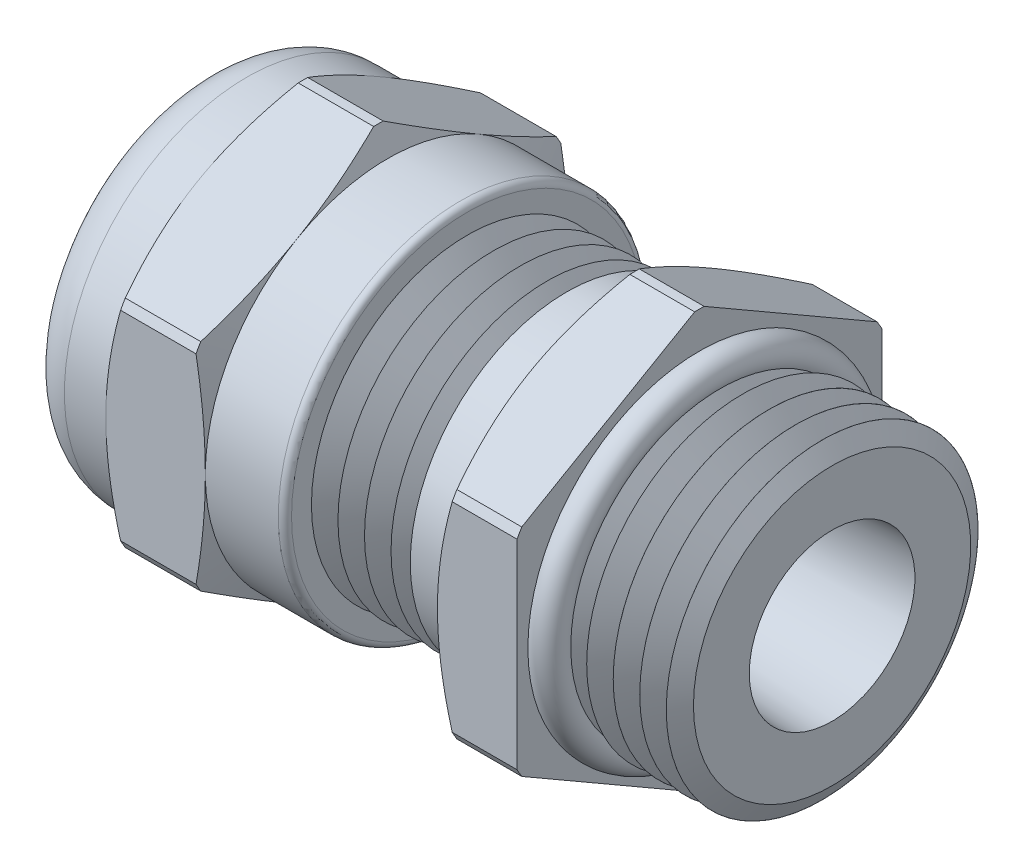
from build123d import *

# Parameters (mm, degrees)
SKETCH6_OUTSIDE_W  = 24.528
SKETCH6_OUTSIDE_H  = 24.528
CUT_EXTRUDE2_DEPTH = 15.748
SKETCH7_OUTSIDE_W  = 31.19
SKETCH7_OUTSIDE_H  = 33.146
SKETCH7_OUTSIDE_R  = 6.985
CUT_EXTRUDE3_DEPTH = 2.54
CUT_EXTRUDE3_DRAFT = -60
SKETCH8_OUTSIDE_W  = 36.35
SKETCH8_OUTSIDE_H  = 38.306
SKETCH8_OUTSIDE_R  = 6.985
CUT_EXTRUDE4_DEPTH = 2.54
CUT_EXTRUDE4_DRAFT = -70
SKETCH9_OUTSIDE_W  = 54.012
SKETCH9_OUTSIDE_H  = 55.968
SKETCH9_OUTSIDE_R  = 6.985
CUT_EXTRUDE5_DEPTH = 9.128
CUT_EXTRUDE5_DRAFT = -60
FILLET1_R          = 1.7145
LPATTERN1_COUNT    = 6
LPATTERN1_PITCH    = 1.016
LPATTERN2_COUNT    = 5
LPATTERN2_PITCH    = 1.016
SKETCH16_R         = 5.9944
SKETCH16_R_2       = 3.172299857
EXTRUDE4_DEPTH     = 2.032
FILLET5_R          = 0.254
SKETCH18_R         = 0.635


with BuildPart() as part:
    # Sketch2 → Revolve1 (revolve)
    with BuildSketch(Plane.XY, mode=Mode.PRIVATE) as revolve1_sk:
        Polygon((-12.065, 5.064125), (-12.065, 6.985), (-8.763, 6.985), (-8.763, 7.9629), (-4.953, 7.9629), (-4.953, 6.985), (-1.905, 6.985), (-1.905, 5.969), (3.937, 5.969), (3.937, 7.9629), (6.985, 7.9629), (6.985, 5.969), (12.065, 5.968911337), (12.065, 3.172299857), (0, 2.54), (-8.763, 2.54), (-8.763, 5.064125), align=None)
    revolve(revolve1_sk.sketch.rotate(Axis((-69.075133251, 0, 0), (1, 0, 0)), 90), axis=Axis((-69.075133251, 0, 0), (1, 0, 0)))  # turned: the seam where the file's is

    # Sketch6 outside → Cut-Extrude2 (cut)
    with BuildSketch(Plane(origin=(6.985, 0, 0), x_dir=(0, 0, -1), z_dir=(1, 0, 0))):
        Rectangle(SKETCH6_OUTSIDE_W, SKETCH6_OUTSIDE_H)
        with BuildLine():
            Line((6.985, -3.823290652), (6.985, 3.823290652))
            ThreePointArc((6.985, 3.823290652), (6.896073688, 3.98145), (6.803566831, 4.137542119))
            Line((6.803566831, 4.137542119), (0.181433169, 7.960832771))
            ThreePointArc((0.181433169, 7.960832771), (0, 7.9629), (-0.181433169, 7.960832771))
            Line((-0.181433169, 7.960832771), (-6.803566831, 4.137542119))
            ThreePointArc((-6.803566831, 4.137542119), (-6.896073688, 3.98145), (-6.985, 3.823290652))
            Line((-6.985, 3.823290652), (-6.985, -3.823290652))
            ThreePointArc((-6.985, -3.823290652), (-6.896073688, -3.98145), (-6.803566831, -4.137542119))
            Line((-6.803566831, -4.137542119), (-0.181433169, -7.960832771))
            ThreePointArc((-0.181433169, -7.960832771), (0, -7.9629), (0.181433169, -7.960832771))
            Line((0.181433169, -7.960832771), (6.803566831, -4.137542119))
            ThreePointArc((6.803566831, -4.137542119), (6.896073688, -3.98145), (6.985, -3.823290652))
        make_face(mode=Mode.SUBTRACT)
    extrude(amount=-CUT_EXTRUDE2_DEPTH, mode=Mode.SUBTRACT)


with BuildPart() as cut_extrude3_tool:
    # Sketch7 outside → Cut-Extrude3 (with draft: the straight prism first)
    with BuildSketch(Plane.ZY.offset(8.763)):
        Rectangle(SKETCH7_OUTSIDE_W, SKETCH7_OUTSIDE_H)
        Circle(SKETCH7_OUTSIDE_R, mode=Mode.SUBTRACT)
    extrude(amount=-CUT_EXTRUDE3_DEPTH)
    # Cut-Extrude3: the draft: its side faces are tilted about the plane it starts from
    cut_extrude3_sides = [cut_extrude3_tool.faces().sort_by_distance(p)[0] for p in [
        (-7.493, -16.573, 0),
        (-7.493, 0, 15.595),
        (-7.493, 16.573, 0),
        (-7.493, 0, -15.595),
        (-7.493, 0, -6.985),
    ]]
    draft(cut_extrude3_sides, Plane.ZY.offset(8.763), CUT_EXTRUDE3_DRAFT)


with BuildPart() as part_1:
    add(part.part)

    # Cut-Extrude3: cut by cut_extrude3_tool
    add(cut_extrude3_tool.part, mode=Mode.SUBTRACT)


with BuildPart() as cut_extrude4_tool:
    # Sketch8 outside → Cut-Extrude4 (with draft: the straight prism first)
    with BuildSketch(Plane(origin=(-4.953, 0, 0), x_dir=(0, 0, -1), z_dir=(1, 0, 0))):
        Rectangle(SKETCH8_OUTSIDE_W, SKETCH8_OUTSIDE_H)
        with Locations(Location((0, 0, 0), (0, 0, 180))):  # turned: the seam where the file's is
            Circle(SKETCH8_OUTSIDE_R, mode=Mode.SUBTRACT)
    extrude(amount=-CUT_EXTRUDE4_DEPTH)
    # Cut-Extrude4: the draft: its side faces are tilted about the plane it starts from
    cut_extrude4_sides = [cut_extrude4_tool.faces().sort_by_distance(p)[0] for p in [
        (-6.223, -19.153, 0),
        (-6.223, 0, -18.175),
        (-6.223, 19.153, 0),
        (-6.223, 0, 18.175),
        (-6.223, 0, -6.985),
    ]]
    draft(cut_extrude4_sides, Plane(origin=(-4.953, 0, 0), x_dir=(0, 0, -1), z_dir=(1, 0, 0)), CUT_EXTRUDE4_DRAFT)


with BuildPart() as part_2:
    add(part_1.part)

    # Cut-Extrude4: cut by cut_extrude4_tool
    add(cut_extrude4_tool.part, mode=Mode.SUBTRACT)


with BuildPart() as cut_extrude5_tool:
    # Sketch9 outside → Cut-Extrude5 (with draft: the straight prism first)
    with BuildSketch(Plane.ZY.offset(-3.937)):
        Rectangle(SKETCH9_OUTSIDE_W, SKETCH9_OUTSIDE_H)
        Circle(SKETCH9_OUTSIDE_R, mode=Mode.SUBTRACT)
    extrude(amount=-CUT_EXTRUDE5_DEPTH)
    # Cut-Extrude5: the draft: its side faces are tilted about the plane it starts from
    cut_extrude5_sides = [cut_extrude5_tool.faces().sort_by_distance(p)[0] for p in [
        (8.501, -27.984, 0),
        (8.501, 0, 27.006),
        (8.501, 27.984, 0),
        (8.501, 0, -27.006),
        (8.501, 0, -6.985),
    ]]
    draft(cut_extrude5_sides, Plane.ZY.offset(-3.937), CUT_EXTRUDE5_DRAFT)


with BuildPart() as part_3:
    add(part_2.part)

    # Cut-Extrude5: cut by cut_extrude5_tool
    add(cut_extrude5_tool.part, mode=Mode.SUBTRACT)

    # Fillet1
    fillet1_edges = [part_3.edges().sort_by_distance(p)[0] for p in [
        (-12.065, 0, -6.985),
    ]]
    fillet(fillet1_edges, radius=FILLET1_R)

    # Sketch13 → Cut-Revolve1 (revolve, cut)
    with BuildSketch(Plane.XY, mode=Mode.PRIVATE) as cut_revolve1_sk:
        Polygon((-1.905, 5.969), (-0.889, 5.969), (-1.397, 5.08911819), align=None)
    cut_revolve1 = revolve(cut_revolve1_sk.sketch.rotate(Axis((-15.434011776, 0, 0), (1, 0, 0)), 90), axis=Axis((-15.434011776, 0, 0), (1, 0, 0)), mode=Mode.SUBTRACT)  # turned: the seam where the file's is

    # LPattern1: Cut-Revolve1 ×6
    with Locations(*[(i * LPATTERN1_PITCH, 0, 0) for i in range(1, LPATTERN1_COUNT)]):
        add(cut_revolve1, mode=Mode.SUBTRACT)

    # Sketch14 → Cut-Revolve2 (revolve, cut)
    with BuildSketch(Plane.XY, mode=Mode.PRIVATE) as cut_revolve2_sk:
        Polygon((7.62, 5.968988917), (8.636, 5.968971185), (8.127984643, 5.089098241), align=None)
    cut_revolve2 = revolve(cut_revolve2_sk.sketch.rotate(Axis((-13.79514925, 0, 0), (1, 0, 0)), 90), axis=Axis((-13.79514925, 0, 0), (1, 0, 0)), mode=Mode.SUBTRACT)  # turned: the seam where the file's is

    # LPattern2: Cut-Revolve2 ×5
    with Locations(*[(i * LPATTERN2_PITCH, 0, 0) for i in range(1, LPATTERN2_COUNT)]):
        add(cut_revolve2, mode=Mode.SUBTRACT)

    # Sketch16 → Extrude4 (add)
    with BuildSketch(Plane.ZY.offset(-3.937)):
        with Locations(Location((0, 0, 0), (0, 0, 180))):  # turned: the seam where the file's is
            Circle(SKETCH16_R)
        Circle(SKETCH16_R_2, mode=Mode.SUBTRACT)
    extrude(amount=EXTRUDE4_DEPTH)

    # Fillet5
    fillet5_edges = [part_3.edges().sort_by_distance(p)[0] for p in [
        (-1.905, 0, -6.985),
    ]]
    fillet(fillet5_edges, radius=FILLET5_R)

    # Sketch18 → Revolve4 (revolve)
    with BuildSketch(Plane.XY, mode=Mode.PRIVATE) as revolve4_sk:
        with Locations((7.1882, 5.968996453)):
            Circle(SKETCH18_R)
    revolve(revolve4_sk.sketch.rotate(Axis((19.121197091, 0, 0), (-1, 0, 0)), 270), axis=Axis((19.121197091, 0, 0), (-1, 0, 0)))  # turned: the seam where the file's is


with BuildPart() as body_2:
    # Sketch12 → Revolve3 (revolve)
    with BuildSketch(Plane.XY, mode=Mode.PRIVATE) as revolve3_sk:
        with BuildLine():
            Line((-8.763, 2.54), (-8.763, 5.064125))
            Line((-8.763, 5.064125), (-11.303, 5.064125))
            ThreePointArc((-11.303, 5.064125), (-11.482605122, 4.989730122), (-11.557, 4.810125))
            Line((-11.557, 4.810125), (-11.557, 2.54))
            Line((-11.557, 2.54), (-8.763, 2.54))
        make_face()
    revolve(revolve3_sk.sketch.rotate(Axis((13.84956521, 0, 0), (-1, 0, 0)), 270), axis=Axis((13.84956521, 0, 0), (-1, 0, 0)))  # turned: the seam where the file's is


solid = Compound([part_3.part, body_2.part])
